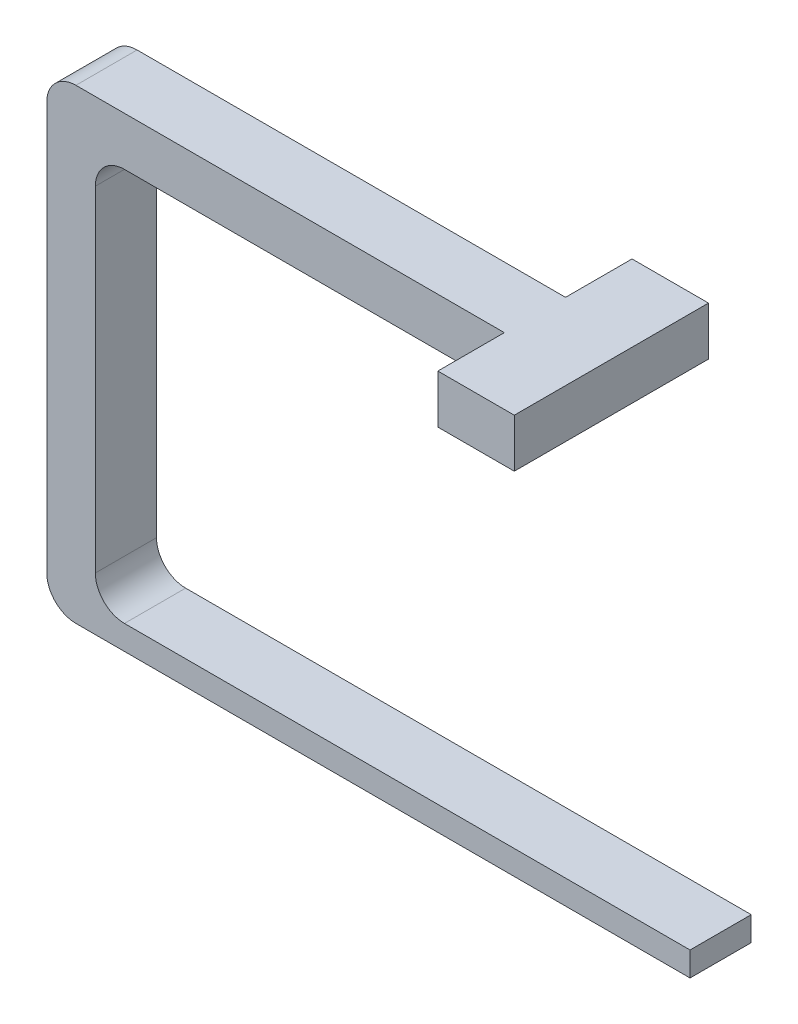
from build123d import *

# Parameters (mm, degrees)
BOSS_EXTRUDE1_DEPTH = 8.001
SKETCH2_W           = 20
SKETCH2_H           = 50.8
BOSS_EXTRUDE2_DEPTH = 12.7
FILLET1_R           = 7.62


with BuildPart() as part:
    # Sketch1 → Boss-Extrude1 (new body, symmetric)
    with BuildSketch(Plane.XY):
        Polygon((-28.575, 115.57), (-168.275, 115.57), (-168.275, 102.87), (-168.275, 0), (-168.275, -6.35), (0, -6.35), (0, 0), (-155.575, 0), (-155.575, 102.87), (-28.575, 102.87), align=None)
    extrude(amount=BOSS_EXTRUDE1_DEPTH, both=True)

    # Sketch2 → Boss-Extrude2 (add)
    with BuildSketch(Plane.XZ.offset(-102.87)):
        with Locations((-38.575, 0)):
            Rectangle(SKETCH2_W, SKETCH2_H)
    extrude(amount=-BOSS_EXTRUDE2_DEPTH)

    # Fillet1
    fillet1_edges = [part.edges().sort_by_distance(p)[0] for p in [
        (-155.575, 102.87, 0),
        (-155.575, 0, 0),
        (-168.275, -6.35, 0),
        (-168.275, 115.57, 0),
    ]]
    fillet(fillet1_edges, radius=FILLET1_R)


solid = part.part
